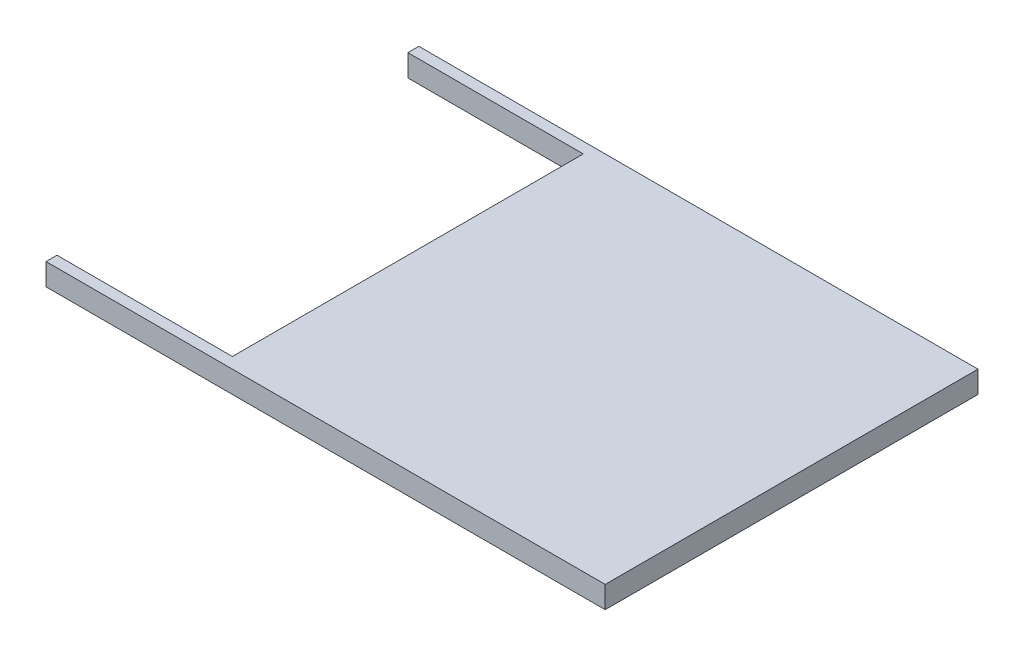
from build123d import *

# Parameters (mm, degrees)
SKETCH1_W               = 257.843094768
SKETCH1_H               = 107.95
BOSS_EXTRUDE1_DEPTH     = 6.35
BOSS_EXTRUDE2_DEPTH     = 19.05
SKETCH3_R               = 0.762
CUT_EXTRUDE1_DEPTH      = 6.35
SKETCH4_W               = 101.6
SKETCH4_H               = 101.6
CUT_EXTRUDE2_DEPTH      = 6.35
CUT_EXTRUDE3_DEPTH      = 35.56
CUT_EXTRUDE3_DEPTH_BACK = 45.974


with BuildPart() as part:
    # Sketch1 → Boss-Extrude1 (new body)
    with BuildSketch(Plane(origin=(0, 0, 0), x_dir=(1, 0, 0), z_dir=(0, 1, 0))):
        Rectangle(SKETCH1_W, SKETCH1_H)
    extrude(amount=-BOSS_EXTRUDE1_DEPTH)

    # Sketch1_3 → Boss-Extrude2 (add)
    with BuildSketch(Plane(origin=(0, 0, 0), x_dir=(1, 0, 0), z_dir=(0, 1, 0))):
        Polygon((-128.921547384, -53.975), (-122.571547384, -53.975), (-122.571547384, -45.339), (-125.746547384, -45.339), (-125.746547384, 45.339), (-122.571547384, 45.339), (-122.571547384, 53.975), (-128.921547384, 53.975), align=None)
        Polygon((-100.092547384, -45.339), (-100.092547384, -53.975), (-93.742547384, -53.975), (-93.742547384, 53.975), (-100.092547384, 53.975), (-100.092547384, 45.339), (-96.917547384, 45.339), (-96.917547384, -45.339), align=None)
    extrude(amount=BOSS_EXTRUDE2_DEPTH)

    # Sketch3 → Cut-Extrude1 (cut)
    with BuildSketch(Plane.XY.offset(53.975)):
        with Locations((-111.332047384, -1.651)):
            Circle(SKETCH3_R)
    cut_extrude1 = extrude(amount=-CUT_EXTRUDE1_DEPTH, mode=Mode.SUBTRACT)

    # Mirror1: Cut-Extrude1 across plane
    add(cut_extrude1.mirror(Plane.XY), mode=Mode.SUBTRACT)

    # Sketch4 → Cut-Extrude2 (cut)
    with BuildSketch(Plane(origin=(0, 0, 0), x_dir=(1, 0, 0), z_dir=(0, 1, 0))):
        with Locations((-33.003452616, 0)):
            Rectangle(SKETCH4_W, SKETCH4_H)
    extrude(amount=-CUT_EXTRUDE2_DEPTH, mode=Mode.SUBTRACT)

    # Sketch5 → Cut-Extrude3 (cut, two sides: drawn at the far end of the back side and taken through both)
    with BuildSketch(Plane(origin=(0, 0, 0), x_dir=(1, 0, 0), z_dir=(0, 1, 0)).offset(-CUT_EXTRUDE3_DEPTH_BACK)):
        Polygon((-33.003452616, -55.428475979), (-33.003452616, -50.8), (-33.003452616, 91.498778784), (-163.947958708, 91.498778784), (-163.947958708, -55.428475979), align=None)
    extrude(amount=CUT_EXTRUDE3_DEPTH + CUT_EXTRUDE3_DEPTH_BACK, mode=Mode.SUBTRACT)


solid = part.part
